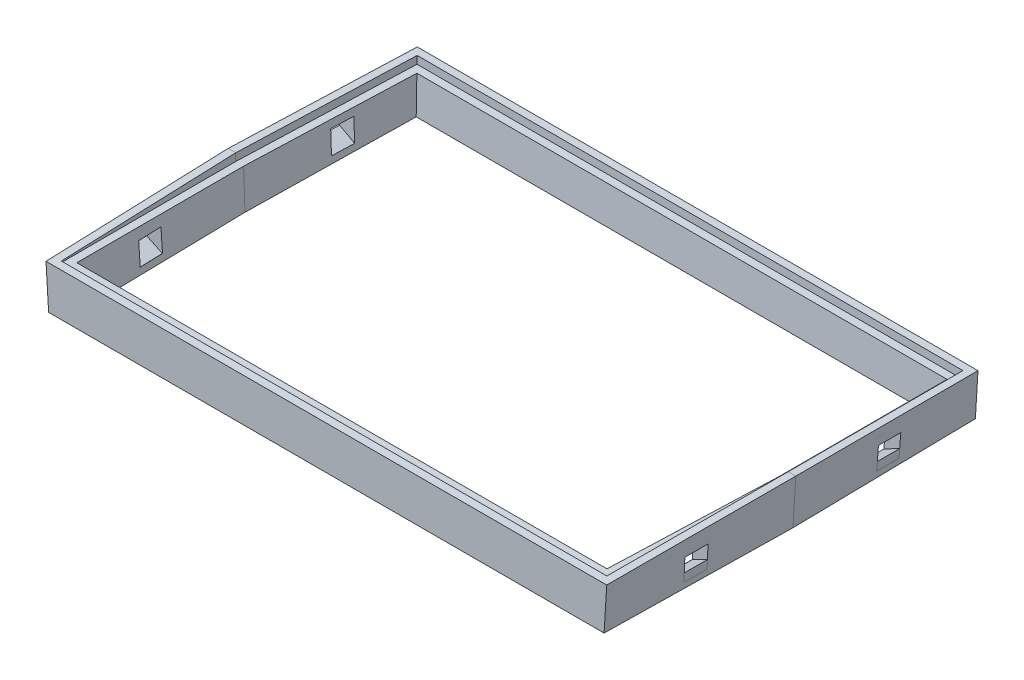
from build123d import *

# Parameters (mm, degrees)
EXTRUDE_1_DEPTH          = 24.5
EXTRUDE_1_DRAFT          = -1
CUT_EXTRUDE_1_REACH      = 120.659
CUT_EXTRUDE_1_DRAFT      = -3
CUT_EXTRUDE_5_DEPTH      = 1
CUT_EXTRUDE_6_DEPTH      = 3
EXTRUDE_2_DEPTH          = 3
MIRROR_6_COPY_1_DEPTH    = 3
MIRROR_6_COPY_2_DEPTH    = 3
SKETCH_16_W              = 97.890152637
SKETCH_16_H              = 76.040955573
CUT_EXTRUDE_7_DEPTH      = 20
CUT_EXTRUDE_7_DEPTH_BACK = 109.33314876


with BuildPart() as part:
    # Sketch 1 → Extrude 1 (with draft: the straight prism first)
    with BuildSketch(Plane.XY):
        Polygon((16.715993843, 25.667879294), (20.215993843, -31.556614873), (87.215993843, -31.556614873), (90.715993843, 25.667879294), align=None)
    extrude(amount=EXTRUDE_1_DEPTH)
    # Extrude 1: the draft: its side faces are tilted about the plane it starts from
    extrude_1_sides = [part.faces().sort_by_distance(p)[0] for p in [
        (18.465993843, -2.94436779, 12.25),
        (53.715993843, -31.556614873, 12.25),
        (88.965993843, -2.94436779, 12.25),
        (53.715993843, 25.667879294, 12.25),
    ]]
    draft(extrude_1_sides, Plane.XY, EXTRUDE_1_DRAFT)

    # Mirror 3: part across plane


with BuildPart() as part_1:
    add(part.part)
    add(part.part.mirror(Plane.XY.offset(24.5)))

    # Cut-Extrude 1: up to this plane
    cut_extrude_1_end = Plane(origin=(20.215993843, -29.556919482, 0.034904813), z_dir=(0, -0.9998476951563913, -0.01745240643728355))



with BuildPart() as cut_extrude_1_long_prism_1:
    # Sketch 2 → Cut-Extrude 1 (the long prism of profile 1, to be tilted and cut off)
    with BuildSketch(Plane(origin=(0, 25.660061204, -0.447898034), x_dir=(1, 0, 0), z_dir=(0, 0.9998476951563913, -0.01745240643728355))):
        Polygon((18.678866318, -47.440503324), (88.753121369, -47.440503324), (89.170598215, -24.951698299), (88.753098752, -2.447966262), (18.678888935, -2.447966262), (18.261389472, -24.951698299), align=None)
    extrude(amount=-CUT_EXTRUDE_1_REACH)
    cut_extrude_1_tool1_sides = [cut_extrude_1_long_prism_1.faces().sort_by_distance(p)[0] for p in [
        (53.715993843, -33.832299375, 48.038274826),
        (88.961859792, -34.028541258, 36.79558489),
        (88.961848484, -34.42115528, 14.302742649),
        (53.715993843, -34.617527418, 3.052590344),
        (18.470139203, -34.42115528, 14.302742649),
        (18.470127895, -34.028541258, 36.79558489),
    ]]
    draft(cut_extrude_1_tool1_sides, Plane(origin=(0, 25.660061204, -0.447898034), x_dir=(1, 0, 0), z_dir=(0, 0.9998476951563913, -0.01745240643728355)), CUT_EXTRUDE_1_DRAFT)  # the draft: side faces tilted about the start plane


with BuildPart() as part_2:
    add(part_1.part)
    cut_extrude_1_tool1 = split(cut_extrude_1_long_prism_1.part, bisect_by=cut_extrude_1_end, keep=Keep.BOTH, mode=Mode.PRIVATE)
    add(cut_extrude_1_tool1.solids().sort_by_distance((53.715994, 26.095398, 24.492555))[0], mode=Mode.SUBTRACT)

    # Sketch 10 → Cut-Extrude 5 (cut)
    with BuildSketch(Plane(origin=(0, 25.660061204, -0.447898034), x_dir=(1, 0, 0), z_dir=(0, 0.9998476951563913, -0.01745240643728355))):
        Polygon((17.697441389, -1.447966262), (89.734546298, -1.447966262), (90.170598215, -24.951698299), (89.714394373, -48.419962311), (17.717593314, -48.419962311), (17.261389472, -24.951698299), align=None)
    extrude(amount=-CUT_EXTRUDE_5_DEPTH, mode=Mode.SUBTRACT)

    # Sketch 13 → Cut-Extrude 6 (cut, symmetric)
    with BuildSketch(Plane(origin=(87.093192584, -4.592650432, -1.535873606), x_dir=(0.017583201594826382, -0.0009272079251698135, 0.999844973636983), z_dir=(-0.998457718176913, 0.05265127083073426, 0.017607631665297937))):
        Polygon((14.826718303, 28.545615626), (14.87901891, 25.545615626), (11.87901891, 25.493315019), (11.826718303, 28.493315019), align=None)
    cut_extrude_6 = extrude(amount=CUT_EXTRUDE_6_DEPTH, both=True, mode=Mode.SUBTRACT)

    # Sketch 14 → Extrude 2 (add)
    with BuildSketch(Plane(origin=(0.283433717, 0.252501642, 15.317338252), x_dir=(-0.9998288893890833, 0.00030489955637755267, 0.018495917907816833), z_dir=(-0.018498430825131588, -0.016479634824702716, -0.9996930677428209))):
        Polygon((-88.431728934, 20.680996021), (-90.383068209, 20.578695502), (-90.452019303, 21.71033965), align=None)
    extrude_2 = extrude(amount=EXTRUDE_2_DEPTH)

    # Mirror 4: Cut-Extrude 6, Extrude 2 across plane
    add(cut_extrude_6.mirror(Plane(origin=(53.715993843, 0, 0), x_dir=(0, 0, 1), z_dir=(1, 0, 0))), mode=Mode.SUBTRACT)
    add(extrude_2.mirror(Plane(origin=(53.715993843, 0, 0), x_dir=(0, 0, 1), z_dir=(1, 0, 0))))

    # Mirror 6: Cut-Extrude 6, Extrude 2 across plane
    add(cut_extrude_6.mirror(Plane.XY.offset(24.5)), mode=Mode.SUBTRACT)
    add(extrude_2.mirror(Plane.XY.offset(24.5)))

    # Mirror 6 copy 1 sketch → Mirror 6 copy 1 (cut, symmetric)
    with BuildSketch(Plane(origin=(20.338795103, -4.592650432, 50.535873606), x_dir=(-0.017583201594826382, -0.0009272079251698135, -0.999844973636983), z_dir=(0.998457718176913, 0.05265127083073426, -0.017607631665297937))):
        Polygon((14.826718303, 28.545615626), (14.87901891, 25.545615626), (11.87901891, 25.493315019), (11.826718303, 28.493315019), align=None)
    extrude(amount=MIRROR_6_COPY_1_DEPTH, both=True, mode=Mode.SUBTRACT)

    # Mirror 6 copy 2 sketch → Mirror 6 copy 2 (add)
    with BuildSketch(Plane(origin=(107.14855397, 0.252501642, 33.682661748), x_dir=(0.9998288893890833, 0.00030489955637755267, -0.018495917907816833), z_dir=(0.018498430825131588, -0.016479634824702716, 0.9996930677428209))):
        Polygon((-88.431728934, 20.680996021), (-90.383068209, 20.578695502), (-90.452019303, 21.71033965), align=None)
    extrude(amount=MIRROR_6_COPY_2_DEPTH)

    # Sketch 16 → Cut-Extrude 7 (cut, two sides)
    with BuildSketch(Plane(origin=(0, 0, 0), x_dir=(1, 0, 0), z_dir=(0, 1, 0))) as cut_extrude_7_sk:
        with Locations((56.945180684, -27.590511427)):
            Rectangle(SKETCH_16_W, SKETCH_16_H)
    extrude(amount=CUT_EXTRUDE_7_DEPTH, mode=Mode.SUBTRACT)
    extrude(cut_extrude_7_sk.sketch, amount=-CUT_EXTRUDE_7_DEPTH_BACK, mode=Mode.SUBTRACT)


solid = part_2.part
